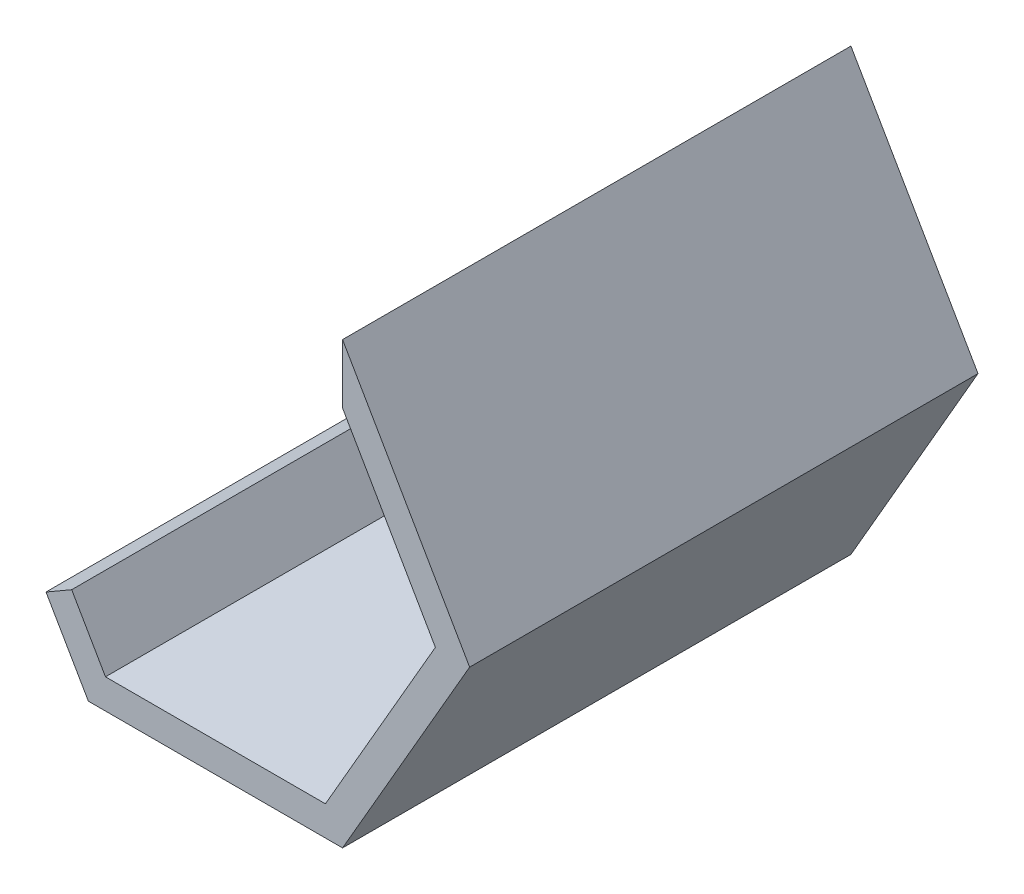
from build123d import *

# Parameters (mm, degrees)
SALIENTE_EXTRUIR1_DEPTH = 120


with BuildPart() as part:
    # Croquis1 → Saliente-Extruir1 (new body)
    with BuildSketch(Plane.XY):
        Polygon((-148.61681164, -25.466374827), (-88.61681164, -25.466374827), (-58.61681164, 26.4951494), (-88.61681164, 78.456673627), (-88.61681164, 68.635843337), (-88.61681164, 64.456673627), (-82.280055586, 53.481090185), (-66.699715409, 26.4951494), (-92.658263524, -18.466374827), (-144.575359756, -18.466374827), (-152.554633813, -4.645866752), (-158.61681164, -8.145866752), align=None)
    extrude(amount=SALIENTE_EXTRUIR1_DEPTH)


solid = part.part
